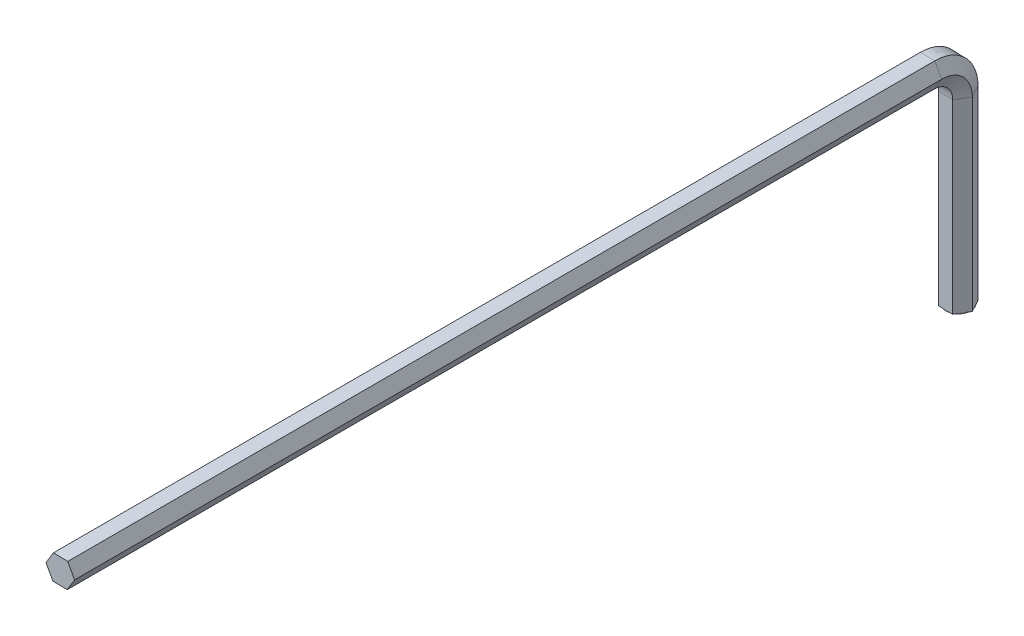
from build123d import *

# Parameters (mm, degrees)
SKETCH2_R           = 2
BOSS_EXTRUDE1_DEPTH = 0.1


with BuildPart() as part:
    # Sweep1: sweep along a curve in space
    with BuildLine() as sweep1_path:
        Line((0, 0, 0), (0, 30, 0))
        ThreePointArc((0, 35, 5), (0, 33.535533906, 1.464466094), (0, 30, 0))
        Line((0, 35, 5), (0, 35, 145))
    # Sketch1 → Sweep1 (sweep)
    with BuildSketch(Plane(origin=(0, 0, 0), x_dir=(-1, 0, 0), z_dir=(0, 1, 0))):
        Polygon((2.308874637, -0.049307649), (1.197138995, 1.974890265), (-1.111735642, 2.024197914), (-2.308874637, 0.049307649), (-1.197138995, -1.974890265), (1.111735642, -2.024197914), align=None)
    sweep(path=sweep1_path.line)

    # Sketch2 → Boss-Extrude1 (add)
    with BuildSketch(Plane.XZ):
        Circle(SKETCH2_R)
    extrude(amount=BOSS_EXTRUDE1_DEPTH)


solid = part.part
